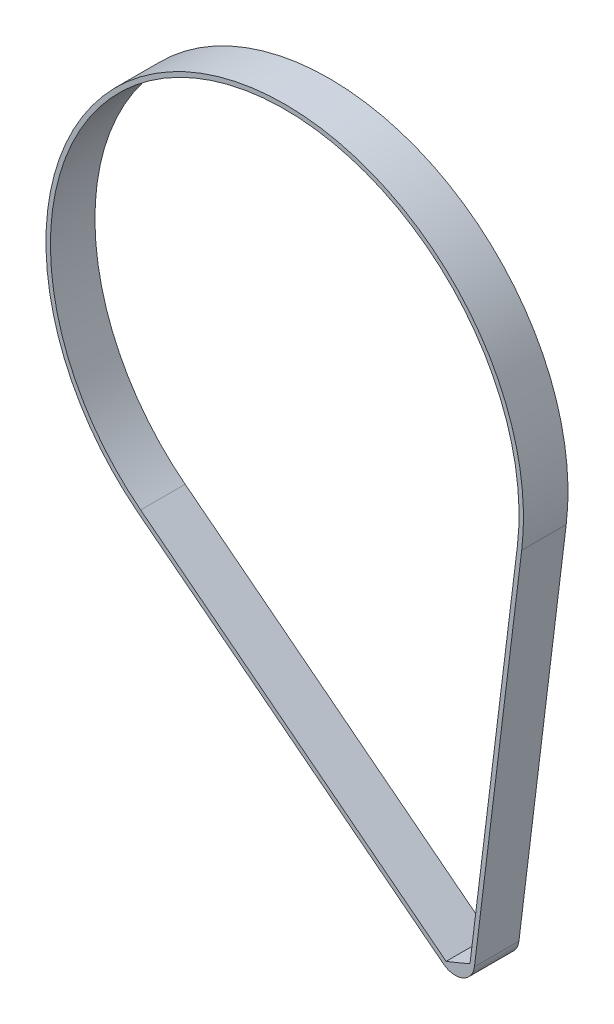
from build123d import *

# Parameters (mm, degrees)
BOSS_EXTRUDE1_DEPTH = 30


with BuildPart() as part:
    # Sketch1 → Boss-Extrude1 (new body)
    with BuildSketch(Plane.XY):
        with BuildLine():
            Line((159.686268065, -19.644029408), (127.81744022, -278.705654725))
            ThreePointArc((127.81744022, -278.705654725), (119.894339524, -289.126870682), (106.921554827, -287.370703297))
            Line((106.921554827, -287.370703297), (-98.92442431, -126.884003621))
            ThreePointArc((-98.92442431, -126.884003621), (-61.628754907, 148.618601355), (159.686268065, -19.644029408))
        make_face()
        with BuildLine():
            Line((156.708713188, -19.277741334), (124.839885343, -278.339366651))
            ThreePointArc((124.839885343, -278.339366651), (116.836842152, -281.753673158), (108.766127348, -285.004788629))
            Line((108.766127348, -285.004788629), (-97.079851789, -124.518088953))
            ThreePointArc((-97.079851789, -124.518088953), (-60.479607883, 145.84741729), (156.708713188, -19.277741334))
        make_face(mode=Mode.SUBTRACT)
    extrude(amount=-BOSS_EXTRUDE1_DEPTH)


solid = part.part
